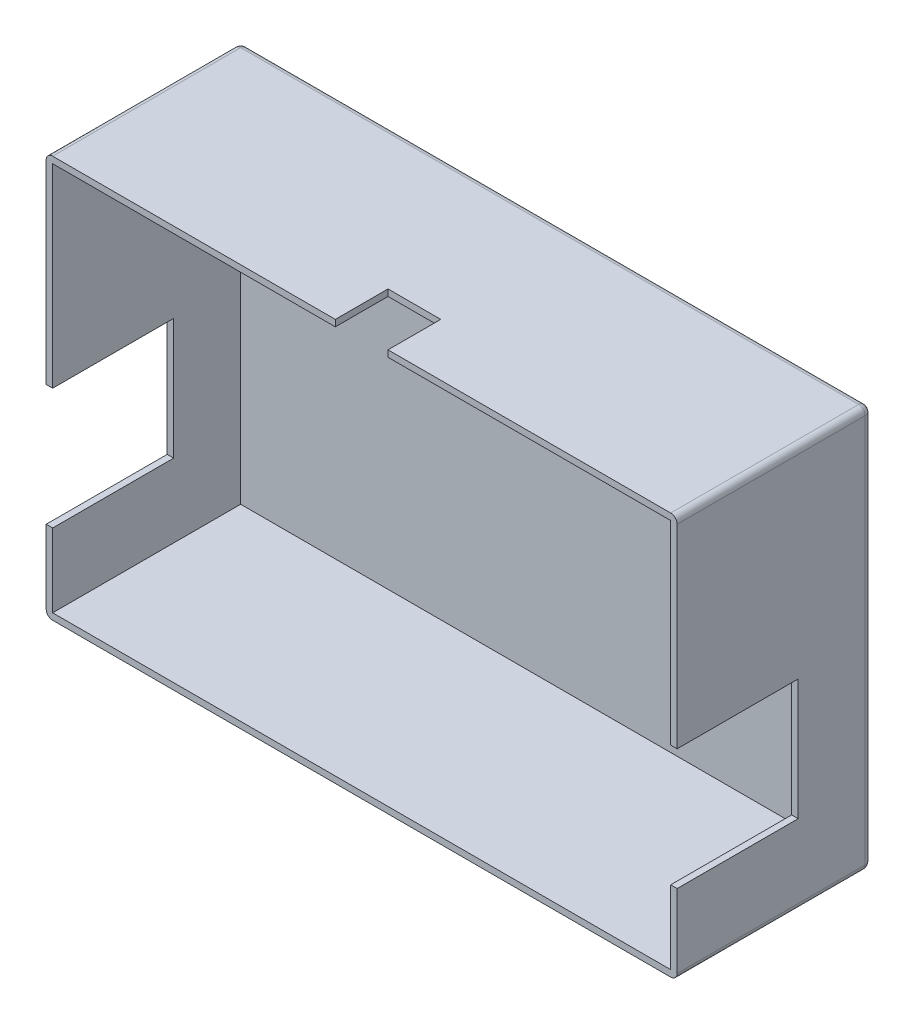
from build123d import *

# Parameters (mm, degrees)
SKETCH_1_W          = 146
SKETCH_1_H          = 45
EXTRUDE_1_DEPTH     = 93
SHELL_1_T           = -1.5
SKETCH_2_W          = 28
SKETCH_2_H          = 28
CUT_EXTRUDE_1_DEPTH = 1.5
SKETCH_4_W          = 12.2
SKETCH_4_H          = 12.2
CUT_EXTRUDE_2_DEPTH = 1.5
FILLET_1_R          = 1.5


with BuildPart() as part:
    # 草图1 → 凸台-拉伸1 (new body)
    with BuildSketch(Plane(origin=(0, 0, 0), x_dir=(1, 0, 0), z_dir=(0, 1, 0))):
        Rectangle(SKETCH_1_W, SKETCH_1_H)
    extrude(amount=EXTRUDE_1_DEPTH)

    # 抽壳1
    shell_1_openings = [part.faces().sort_by_distance(p)[0] for p in [
        (0, 46.5, 22.5),
    ]]
    offset(amount=SHELL_1_T, openings=shell_1_openings, kind=Kind.INTERSECTION)

    # 草图2 → 切除-拉伸1 (cut)
    with BuildSketch(Plane.ZY.offset(73)):
        with Locations((8.5, 32.5)):
            Rectangle(SKETCH_2_W, SKETCH_2_H)
    cut_extrude_1 = extrude(amount=-CUT_EXTRUDE_1_DEPTH, mode=Mode.SUBTRACT)

    # 草图4 → 切除-拉伸2 (cut)
    with BuildSketch(Plane(origin=(0, 93, 0), x_dir=(1, 0, 0), z_dir=(0, 1, 0))):
        with Locations((0, -16.4)):
            Rectangle(SKETCH_4_W, SKETCH_4_H)
    extrude(amount=-CUT_EXTRUDE_2_DEPTH, mode=Mode.SUBTRACT)

    # 镜向1: 切除-拉伸1 across plane
    add(cut_extrude_1.mirror(Plane(origin=(0, 0, 0), x_dir=(0, 0, 1), z_dir=(1, 0, 0))), mode=Mode.SUBTRACT)

    # 圆角1
    fillet_1_edges = [part.edges().sort_by_distance(p)[0] for p in [
        (-73, 93, 0),
        (73, 93, 0),
        (-73, 0, 0),
        (0, 0, -22.5),
        (73, 0, 0),
        (-73, 46.5, -22.5),
        (73, 46.5, -22.5),
        (0, 93, -22.5),
    ]]
    fillet(fillet_1_edges, radius=FILLET_1_R)


solid = part.part
